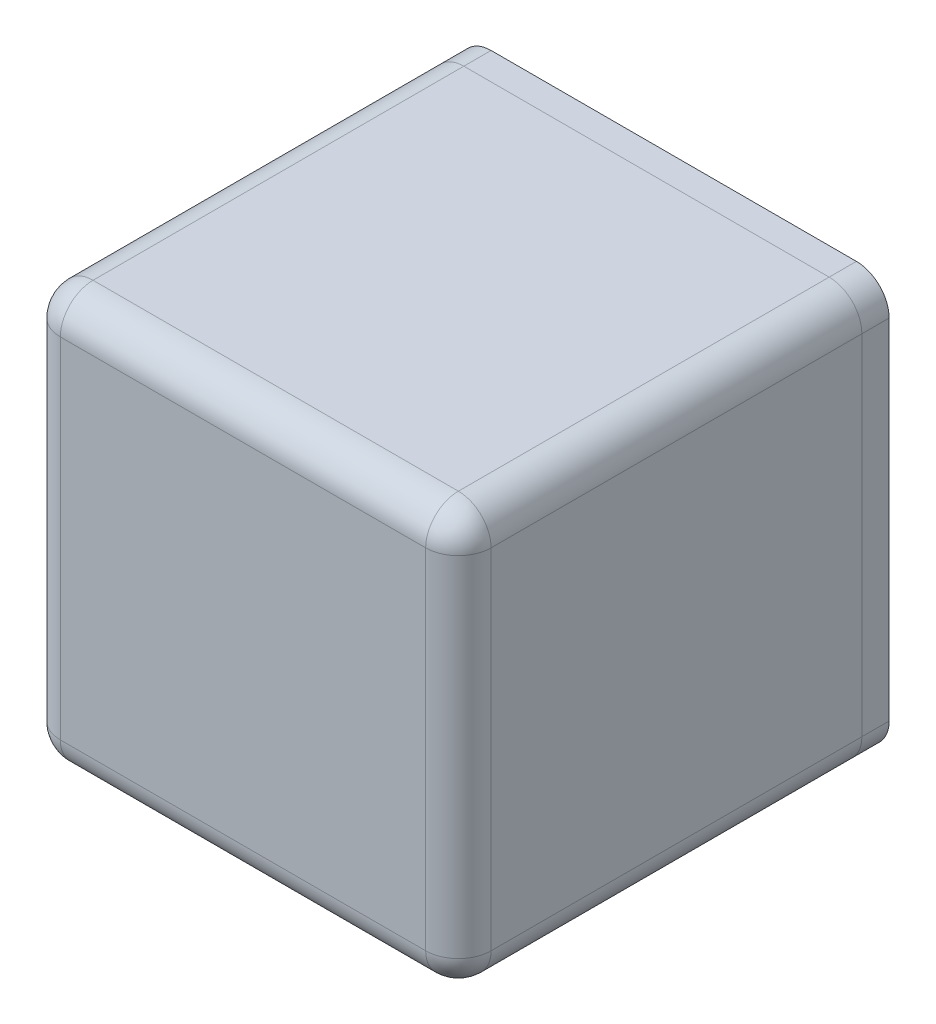
from build123d import *

# Parameters (mm, degrees)
SKETCH3_W           = 37
SKETCH3_H           = 38
BOSS_EXTRUDE3_DEPTH = 19.75
FILLET1_R           = 3
SHELL2_T            = -2
BOSS_EXTRUDE5_REACH = 39
SKETCH6_R           = 1.25
SKETCH8_W           = 7
SKETCH8_H           = 9.1
BOSS_EXTRUDE6_DEPTH = 8
CUT_EXTRUDE2_DEPTH  = 3
SKETCH9_R           = 1.25
BOSS_EXTRUDE7_DEPTH = 1
BOSS_EXTRUDE7_TAPER = 5
SKETCH5_R           = 1.337488664
BOSS_EXTRUDE4_DEPTH = 2.5
BOSS_EXTRUDE8_DEPTH = 1.5
CUT_EXTRUDE3_DEPTH  = 1
CUT_EXTRUDE4_DEPTH  = 1.5
CUT_EXTRUDE5_START  = -39.5
SKETCH17_W          = 15
SKETCH17_H          = 31
CUT_EXTRUDE5_DEPTH  = 39.5


with BuildPart() as part:
    # Sketch3 → Boss-Extrude3 (new body, symmetric)
    with BuildSketch(Plane(origin=(0, 0, 0), x_dir=(0, 0, -1), z_dir=(1, 0, 0))):
        Rectangle(SKETCH3_W, SKETCH3_H)
    extrude(amount=BOSS_EXTRUDE3_DEPTH, both=True)

    # Fillet1
    fillet1_edges = [part.edges().sort_by_distance(p)[0] for p in [
        (19.75, 0, 18.5),
        (19.75, -19, 0),
        (-19.75, -19, 0),
        (-19.75, 0, 18.5),
        (-19.75, 19, 0),
        (19.75, 19, 0),
        (0, -19, 18.5),
        (0, 19, 18.5),
    ]]
    fillet(fillet1_edges, radius=FILLET1_R)

    # Shell2
    shell2_openings = [part.faces().sort_by_distance(p)[0] for p in [
        (0, 0, -18.5),
    ]]
    offset(amount=SHELL2_T, openings=shell2_openings, kind=Kind.INTERSECTION)

    # Sketch6 → Boss-Extrude5 (add, up to next)
    with BuildSketch(Plane(origin=(0, 0, -18.5), x_dir=(-1, 0, 0), z_dir=(0, 0, -1)), mode=Mode.PRIVATE) as boss_extrude5_sk1:
        with BuildLine():
            Line((-13.5, 15.5), (-13.5, 18.25))
            Line((-13.5, 18.25), (-16.25, 18.25))
            ThreePointArc((-16.25, 18.25), (-18.194543648, 17.444543648), (-19, 15.5))
            Line((-19, 15.5), (-19, 12.75))
            Line((-19, 12.75), (-16.25, 12.75))
            ThreePointArc((-16.25, 12.75), (-14.305456352, 13.555456352), (-13.5, 15.5))
        make_face()
        with Locations((-16.25, 15.5)):
            Circle(SKETCH6_R, mode=Mode.SUBTRACT)
    boss_extrude5_tool1 = extrude(boss_extrude5_sk1.sketch, amount=-BOSS_EXTRUDE5_REACH, mode=Mode.PRIVATE) - part.part
    add(boss_extrude5_tool1.solids().sort_by_distance((13.577782, 16.875, -18.5))[0])
    # Sketch6 → Boss-Extrude5 (add, up to next)
    with BuildSketch(Plane(origin=(0, 0, -18.5), x_dir=(-1, 0, 0), z_dir=(0, 0, -1)), mode=Mode.PRIVATE) as boss_extrude5_sk2:
        with BuildLine():
            Line((-19, -12.75), (-16.25, -12.75))
            ThreePointArc((-16.25, -12.75), (-14.305456352, -13.555456352), (-13.5, -15.5))
            Line((-13.5, -15.5), (-13.5, -18.25))
            Line((-13.5, -18.25), (-16.25, -18.25))
            ThreePointArc((-16.25, -18.25), (-18.194543648, -17.444543648), (-19, -15.5))
            Line((-19, -15.5), (-19, -12.75))
        make_face()
        with Locations((-16.25, -15.5)):
            Circle(SKETCH6_R, mode=Mode.SUBTRACT)
    boss_extrude5_tool2 = extrude(boss_extrude5_sk2.sketch, amount=-BOSS_EXTRUDE5_REACH, mode=Mode.PRIVATE) - part.part
    add(boss_extrude5_tool2.solids().sort_by_distance((17.625, -12.827782, -18.5))[0])
    # Sketch6 → Boss-Extrude5 (add, up to next)
    with BuildSketch(Plane(origin=(0, 0, -18.5), x_dir=(-1, 0, 0), z_dir=(0, 0, -1)), mode=Mode.PRIVATE) as boss_extrude5_sk3:
        with BuildLine():
            Line((13.5, -15.5), (13.5, -18.25))
            Line((13.5, -18.25), (16.25, -18.25))
            ThreePointArc((16.25, -18.25), (18.194543648, -17.444543648), (19, -15.5))
            Line((19, -15.5), (19, -12.75))
            Line((19, -12.75), (16.25, -12.75))
            ThreePointArc((16.25, -12.75), (14.305456352, -13.555456352), (13.5, -15.5))
        make_face()
        with Locations((16.25, -15.5)):
            Circle(SKETCH6_R, mode=Mode.SUBTRACT)
    boss_extrude5_tool3 = extrude(boss_extrude5_sk3.sketch, amount=-BOSS_EXTRUDE5_REACH, mode=Mode.PRIVATE) - part.part
    add(boss_extrude5_tool3.solids().sort_by_distance((-13.577782, -16.875, -18.5))[0])
    # Sketch6 → Boss-Extrude5 (add, up to next)
    with BuildSketch(Plane(origin=(0, 0, -18.5), x_dir=(-1, 0, 0), z_dir=(0, 0, -1)), mode=Mode.PRIVATE) as boss_extrude5_sk4:
        with BuildLine():
            Line((19, 12.75), (16.25, 12.75))
            ThreePointArc((16.25, 12.75), (14.305456352, 13.555456352), (13.5, 15.5))
            Line((13.5, 15.5), (13.5, 18.25))
            Line((13.5, 18.25), (16.25, 18.25))
            ThreePointArc((16.25, 18.25), (18.194543648, 17.444543648), (19, 15.5))
            Line((19, 15.5), (19, 12.75))
        make_face()
        with Locations((16.25, 15.5)):
            Circle(SKETCH6_R, mode=Mode.SUBTRACT)
    boss_extrude5_tool4 = extrude(boss_extrude5_sk4.sketch, amount=-BOSS_EXTRUDE5_REACH, mode=Mode.PRIVATE) - part.part
    add(boss_extrude5_tool4.solids().sort_by_distance((-18.139544, 17.389544, -18.5))[0])

    # Sketch8 → Boss-Extrude6 (add)
    with BuildSketch(Plane(origin=(0, 0, 16.5), x_dir=(-1, 0, 0), z_dir=(0, 0, -1))):
        with BuildLine():
            Line((10.75, 17), (13.5, 17))
            Line((13.5, 17), (13.5, 15.5))
            ThreePointArc((13.5, 15.5), (14.305456352, 13.555456352), (16.25, 12.75))
            Line((16.25, 12.75), (17.75, 12.75))
            Line((17.75, 12.75), (17.75, 9.5248))
            Line((17.75, 9.5248), (10.75, 9.5248))
            Line((10.75, 9.5248), (10.75, 17))
        make_face()
        with Locations((14.25, -0.9252)):
            Rectangle(SKETCH8_W, SKETCH8_H)
        with BuildLine():
            Line((13.5, -17), (13.5, -15.5))
            ThreePointArc((13.5, -15.5), (14.305456352, -13.555456352), (16.25, -12.75))
            Line((16.25, -12.75), (17.75, -12.75))
            Line((17.75, -12.75), (17.75, -11.3752))
            Line((17.75, -11.3752), (10.75, -11.3752))
            Line((10.75, -11.3752), (10.75, -17))
            Line((10.75, -17), (13.5, -17))
        make_face()
    extrude(amount=BOSS_EXTRUDE6_DEPTH)

    # Sketch4 → Cut-Extrude2 (cut)
    with BuildSketch(Plane(origin=(-19.75, 0, 0), x_dir=(0, 0, -1), z_dir=(1, 0, 0))):
        with BuildLine():
            Line((-5.7, 10.624800233), (-14.6, 10.624800233))
            ThreePointArc((-14.6, 10.624800233), (-15.307106781, 10.331907014), (-15.6, 9.624800233))
            Line((-15.6, 9.624800233), (-15.6, 3.524800233))
            ThreePointArc((-15.6, 3.524800233), (-15.307106781, 2.817693452), (-14.6, 2.524800233))
            Line((-14.6, 2.524800233), (-5.7, 2.524800233))
            ThreePointArc((-5.7, 2.524800233), (-4.992893219, 2.817693452), (-4.7, 3.524800233))
            Line((-4.7, 3.524800233), (-4.7, 9.624800233))
            ThreePointArc((-4.7, 9.624800233), (-4.992893219, 10.331907014), (-5.7, 10.624800233))
        make_face()
        with BuildLine():
            Line((-14.6, -4.375199767), (-5.7, -4.375199767))
            ThreePointArc((-5.7, -4.375199767), (-4.992893219, -4.668092986), (-4.7, -5.375199767))
            Line((-4.7, -5.375199767), (-4.7, -11.475199767))
            ThreePointArc((-4.7, -11.475199767), (-4.992893219, -12.182306548), (-5.7, -12.475199767))
            Line((-5.7, -12.475199767), (-14.6, -12.475199767))
            ThreePointArc((-14.6, -12.475199767), (-15.307106781, -12.182306548), (-15.6, -11.475199767))
            Line((-15.6, -11.475199767), (-15.6, -5.375199767))
            ThreePointArc((-15.6, -5.375199767), (-15.307106781, -4.668092986), (-14.6, -4.375199767))
        make_face()
    extrude(amount=CUT_EXTRUDE2_DEPTH, mode=Mode.SUBTRACT)

    # Sketch9 → Boss-Extrude7 (add)
    with BuildSketch(Plane(origin=(0, 0, -18.5), x_dir=(-1, 0, 0), z_dir=(0, 0, -1))):
        with BuildLine():
            Line((16.75, 18), (-16.75, 18))
            ThreePointArc((-16.75, 18), (-18.164213562, 17.414213562), (-18.75, 16))
            Line((-18.75, 16), (-18.75, -16))
            ThreePointArc((-18.75, -16), (-18.164213562, -17.414213562), (-16.75, -18))
            Line((-16.75, -18), (16.75, -18))
            ThreePointArc((16.75, -18), (18.164213562, -17.414213562), (18.75, -16))
            Line((18.75, -16), (18.75, 16))
            ThreePointArc((18.75, 16), (18.164213562, 17.414213562), (16.75, 18))
        make_face()
        with Locations((-16.25, 15.5)):
            Circle(SKETCH9_R, mode=Mode.SUBTRACT)
        with Locations((16.25, 15.5)):
            Circle(SKETCH9_R, mode=Mode.SUBTRACT)
        with Locations((16.25, -15.5)):
            Circle(SKETCH9_R, mode=Mode.SUBTRACT)
        with Locations((-16.25, -15.5)):
            Circle(SKETCH9_R, mode=Mode.SUBTRACT)
        with BuildLine():
            Line((-13.5, 17), (-13.5, 15.5))
            ThreePointArc((-13.5, 15.5), (-14.305456352, 13.555456352), (-16.25, 12.75))
            Line((-16.25, 12.75), (-17.75, 12.75))
            Line((-17.75, 12.75), (-17.75, -12.75))
            Line((-17.75, -12.75), (-16.25, -12.75))
            ThreePointArc((-16.25, -12.75), (-14.305456352, -13.555456352), (-13.5, -15.5))
            Line((-13.5, -15.5), (-13.5, -17))
            Line((-13.5, -17), (13.5, -17))
            Line((13.5, -17), (13.5, -15.5))
            ThreePointArc((13.5, -15.5), (14.305456352, -13.555456352), (16.25, -12.75))
            Line((16.25, -12.75), (17.75, -12.75))
            Line((17.75, -12.75), (17.75, 12.75))
            Line((17.75, 12.75), (16.25, 12.75))
            ThreePointArc((16.25, 12.75), (14.305456352, 13.555456352), (13.5, 15.5))
            Line((13.5, 15.5), (13.5, 17))
            Line((13.5, 17), (-13.5, 17))
        make_face(mode=Mode.SUBTRACT)
    extrude(amount=BOSS_EXTRUDE7_DEPTH, taper=BOSS_EXTRUDE7_TAPER)


with BuildPart() as body_2:
    # Sketch5 → Boss-Extrude4 (new body)
    with BuildSketch(Plane(origin=(0, 0, -18.5), x_dir=(-1, 0, 0), z_dir=(0, 0, -1))):
        with BuildLine():
            Line((19.75, -16), (19.75, 16))
            ThreePointArc((19.75, 16), (18.871320344, 18.121320344), (16.75, 19))
            Line((16.75, 19), (-16.75, 19))
            ThreePointArc((-16.75, 19), (-18.871320344, 18.121320344), (-19.75, 16))
            Line((-19.75, 16), (-19.75, -16))
            ThreePointArc((-19.75, -16), (-18.871320344, -18.121320344), (-16.75, -19))
            Line((-16.75, -19), (16.75, -19))
            ThreePointArc((16.75, -19), (18.871320344, -18.121320344), (19.75, -16))
        make_face()
        with Locations((-16.25, 15.5)):
            Circle(SKETCH5_R, mode=Mode.SUBTRACT)
        with Locations((16.25, 15.5)):
            Circle(SKETCH5_R, mode=Mode.SUBTRACT)
        with Locations((16.25, -15.5)):
            Circle(SKETCH5_R, mode=Mode.SUBTRACT)
        with Locations((-16.25, -15.5)):
            Circle(SKETCH5_R, mode=Mode.SUBTRACT)
    extrude(amount=BOSS_EXTRUDE4_DEPTH)

    # Sketch15 → Cut-Extrude3 (cut)
    with BuildSketch(Plane(origin=(0, 0, -18.5), x_dir=(-1, 0, 0), z_dir=(0, 0, -1))):
        with BuildLine():
            Line((-16.75, -18.112511336), (16.75, -18.112511336))
            ThreePointArc((16.75, -18.112511336), (18.243771091, -17.493771091), (18.862511336, -16))
            Line((18.862511336, -16), (18.862511336, 16))
            ThreePointArc((18.862511336, 16), (18.243771091, 17.493771091), (16.75, 18.112511336))
            Line((16.75, 18.112511336), (-16.75, 18.112511336))
            ThreePointArc((-16.75, 18.112511336), (-18.243771091, 17.493771091), (-18.862511336, 16))
            Line((-18.862511336, 16), (-18.862511336, -16))
            ThreePointArc((-18.862511336, -16), (-18.243771091, -17.493771091), (-16.75, -18.112511336))
        make_face()
    extrude(amount=CUT_EXTRUDE3_DEPTH, mode=Mode.SUBTRACT)


with BuildPart() as body_3:
    # Sketch14 → Boss-Extrude8 (new body)
    with BuildSketch(Plane(origin=(0, 0, -19.5), x_dir=(-1, 0, 0), z_dir=(0, 0, -1))):
        with BuildLine():
            Line((17.637488664, -12.637488664), (17.637488664, 12.637488664))
            Line((17.637488664, 12.637488664), (16.25, 12.637488664))
            ThreePointArc((16.25, 12.637488664), (14.225898823, 13.475898823), (13.387488664, 15.5))
            Line((13.387488664, 15.5), (13.387488664, 16.887488664))
            Line((13.387488664, 16.887488664), (-13.387488664, 16.887488664))
            Line((-13.387488664, 16.887488664), (-13.387488664, 15.5))
            ThreePointArc((-13.387488664, 15.5), (-14.225898823, 13.475898823), (-16.25, 12.637488664))
            Line((-16.25, 12.637488664), (-17.637488664, 12.637488664))
            Line((-17.637488664, 12.637488664), (-17.637488664, -12.637488664))
            Line((-17.637488664, -12.637488664), (-16.25, -12.637488664))
            ThreePointArc((-16.25, -12.637488664), (-14.225898823, -13.475898823), (-13.387488664, -15.5))
            Line((-13.387488664, -15.5), (-13.387488664, -16.887488664))
            Line((-13.387488664, -16.887488664), (13.387488664, -16.887488664))
            Line((13.387488664, -16.887488664), (13.387488664, -15.5))
            ThreePointArc((13.387488664, -15.5), (14.225898823, -13.475898823), (16.25, -12.637488664))
            Line((16.25, -12.637488664), (17.637488664, -12.637488664))
        make_face()
    extrude(amount=-BOSS_EXTRUDE8_DEPTH)

    # Combine1: union body 2
    add(body_2.part)

    # Sketch16 → Cut-Extrude4 (cut)
    with BuildSketch(Plane.XY.offset(-18)):
        with BuildLine():
            Line((-11.426220739, -14.887488664), (11.426220739, -14.887488664))
            ThreePointArc((11.426220739, -14.887488664), (12.81168526, -12.06168526), (15.637488664, -10.676220739))
            Line((15.637488664, -10.676220739), (15.637488664, 10.676220739))
            ThreePointArc((15.637488664, 10.676220739), (12.81168526, 12.06168526), (11.426220739, 14.887488664))
            Line((11.426220739, 14.887488664), (-11.426220739, 14.887488664))
            ThreePointArc((-11.426220739, 14.887488664), (-12.81168526, 12.06168526), (-15.637488664, 10.676220739))
            Line((-15.637488664, 10.676220739), (-15.637488664, -10.676220739))
            ThreePointArc((-15.637488664, -10.676220739), (-12.81168526, -12.06168526), (-11.426220739, -14.887488664))
        make_face()
    extrude(amount=-CUT_EXTRUDE4_DEPTH, mode=Mode.SUBTRACT)

    # Sketch17 → Cut-Extrude5 (cut)
    with BuildSketch(Plane(origin=(0, 0, -21), x_dir=(-1, 0, 0), z_dir=(0, 0, -1)).offset(CUT_EXTRUDE5_START)):
        with Locations((-5.25, -3.5)):
            Rectangle(SKETCH17_W, SKETCH17_H)
    extrude(amount=CUT_EXTRUDE5_DEPTH, mode=Mode.SUBTRACT)


solid = Compound([part.part, body_3.part])
